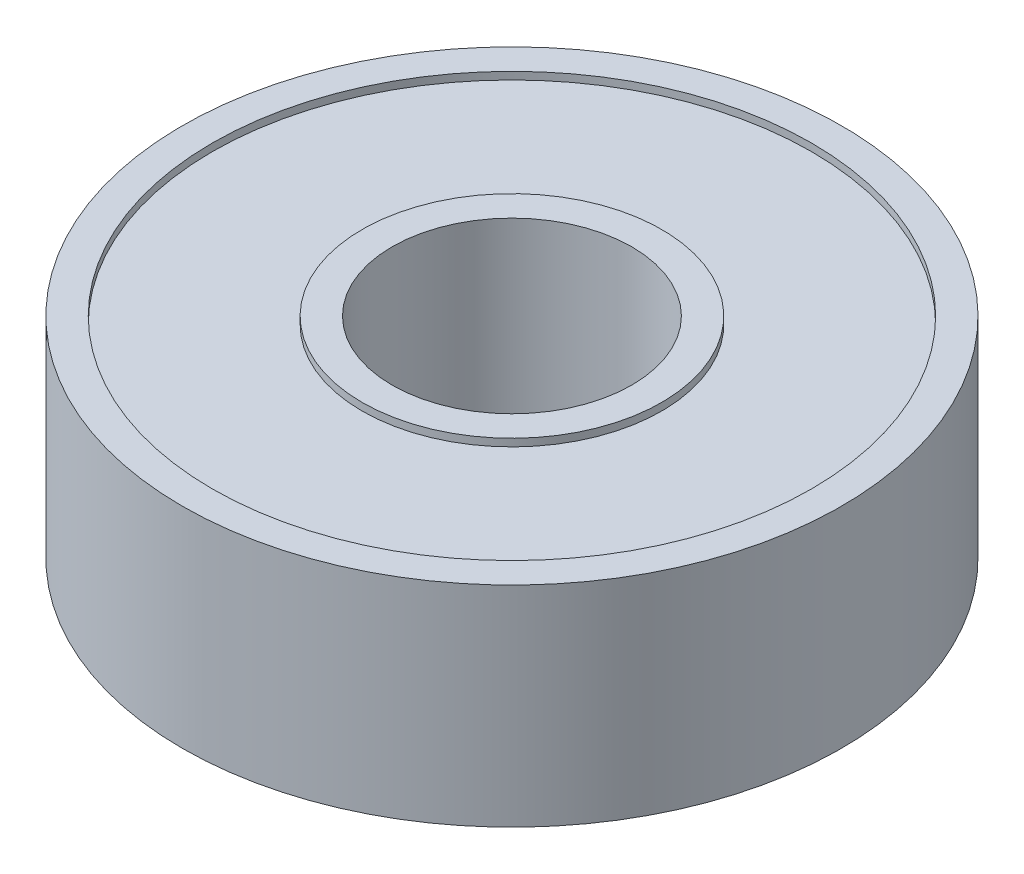
from build123d import *

# Parameters (mm, degrees)
SKETCH1_R           = 11
SKETCH1_R_2         = 4
BOSS_EXTRUDE1_DEPTH = 7
SKETCH2_R           = 10
SKETCH2_R_2         = 5
CUT_EXTRUDE1_DEPTH  = 0.25


with BuildPart() as part:
    # Sketch1 → Boss-Extrude1 (new body)
    with BuildSketch(Plane(origin=(0, 0, 0), x_dir=(1, 0, 0), z_dir=(0, 1, 0))):
        Circle(SKETCH1_R)
        Circle(SKETCH1_R_2, mode=Mode.SUBTRACT)
    extrude(amount=BOSS_EXTRUDE1_DEPTH)

    # Sketch2 → Cut-Extrude1 (cut)
    with BuildSketch(Plane(origin=(0, 7, 0), x_dir=(1, 0, 0), z_dir=(0, 1, 0))):
        Circle(SKETCH2_R)
        Circle(SKETCH2_R_2, mode=Mode.SUBTRACT)
    cut_extrude1 = extrude(amount=-CUT_EXTRUDE1_DEPTH, mode=Mode.SUBTRACT)

    # Mirror1: Cut-Extrude1 across plane
    add(cut_extrude1.mirror(Plane.ZX.offset(3.5)), mode=Mode.SUBTRACT)


solid = part.part
